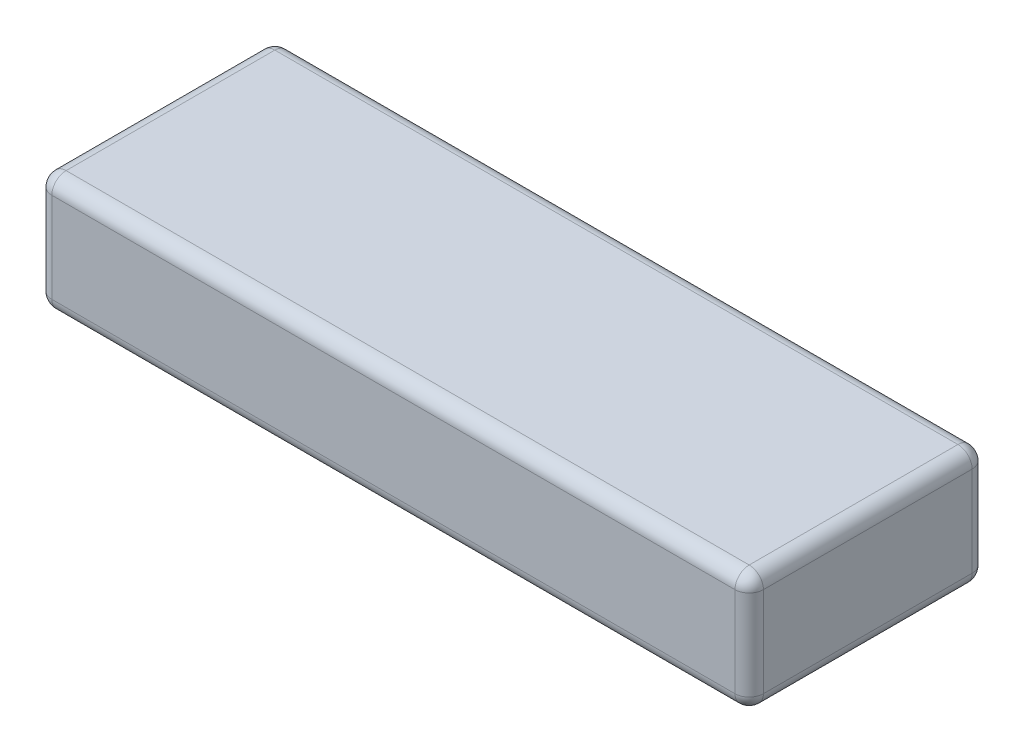
from build123d import *

# Parameters (mm, degrees)
SKETCH_1_W      = 150
SKETCH_1_H      = 50
EXTRUDE_1_DEPTH = 25
FILLET_1_R      = 3


with BuildPart() as part:
    # Эскиз1 → Бобышка-Вытянуть1 (new body)
    with BuildSketch(Plane(origin=(0, 0, 0), x_dir=(1, 0, 0), z_dir=(0, 1, 0))):
        with Locations((75, -25)):
            Rectangle(SKETCH_1_W, SKETCH_1_H)
    extrude(amount=EXTRUDE_1_DEPTH)

    # Скругление1
    fillet_1_edges = [part.edges().sort_by_distance(p)[0] for p in [
        (150, 25, 25),
        (75, 25, 0),
        (0, 25, 25),
        (75, 0, 0),
        (150, 0, 25),
        (75, 0, 50),
        (0, 0, 25),
        (75, 25, 50),
        (0, 12.5, 0),
        (150, 12.5, 0),
        (150, 12.5, 50),
        (0, 12.5, 50),
    ]]
    fillet(fillet_1_edges, radius=FILLET_1_R)


solid = part.part
